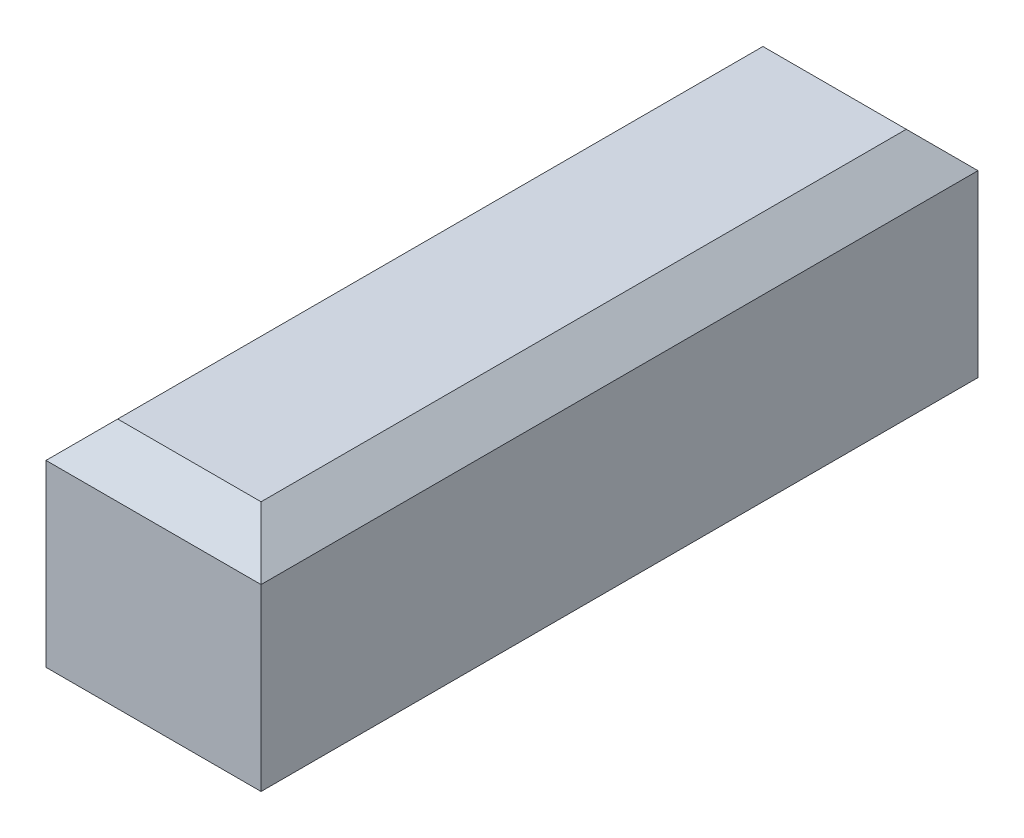
from build123d import *

# Parameters (mm, degrees)
SKETCH1_W           = 18
SKETCH1_H           = 60
BOSS_EXTRUDE1_DEPTH = 18
CHAMFER1_SIZE       = 3


with BuildPart() as part:
    # Sketch1 → Boss-Extrude1 (new body)
    with BuildSketch(Plane(origin=(0, 0, 0), x_dir=(1, 0, 0), z_dir=(0, 1, 0))):
        with Locations((-9, 30)):
            Rectangle(SKETCH1_W, SKETCH1_H)
    extrude(amount=BOSS_EXTRUDE1_DEPTH)

    # Chamfer1
    chamfer1_edges = [part.edges().sort_by_distance(p)[0] for p in [
        (-18, 18, -30),
        (-9, 18, 0),
        (0, 18, -30),
        (-9, 18, -60),
    ]]
    chamfer(chamfer1_edges, length=CHAMFER1_SIZE)


solid = part.part
